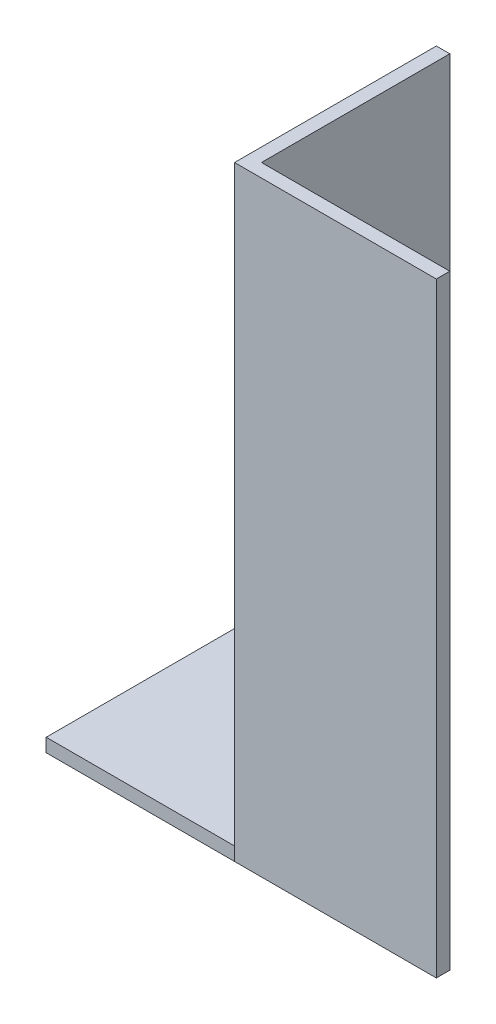
from build123d import *

# Parameters (mm, degrees)
EXTRUDE_1_DEPTH     = 65
SKETCH_3_W          = 1
SKETCH_3_H          = 14
CUT_EXTRUDE_1_DEPTH = 20
SKETCH_5_W          = 14
SKETCH_5_H          = 1
EXTRUDE_4_DEPTH     = 16
SKETCH_6_W          = 15
SKETCH_6_H          = 1
CUT_EXTRUDE_2_DEPTH = 19
SKETCH_7_W          = 15
SKETCH_7_H          = 1
CUT_EXTRUDE_3_DEPTH = 1


with BuildPart() as part:
    # Эскиз1 → Бобышка-Вытянуть1 (new body)
    with BuildSketch(Plane(origin=(0, 0, 0), x_dir=(1, 0, 0), z_dir=(0, 1, 0))):
        Polygon((0, 0), (0, 15), (1, 15), (1, 1), (15, 1), (15, 0), align=None)
    extrude(amount=EXTRUDE_1_DEPTH)

    # Эскиз3 → Вырез-Вытянуть1 (cut)
    with BuildSketch(Plane.XZ):
        with Locations((0.5, -8)):
            Rectangle(SKETCH_3_W, SKETCH_3_H)
    extrude(amount=-CUT_EXTRUDE_1_DEPTH, mode=Mode.SUBTRACT)

    # Эскиз5 → Бобышка-Вытянуть4 (add)
    with BuildSketch(Plane(origin=(1, 0, 0), x_dir=(0, 0, -1), z_dir=(1, 0, 0))):
        with Locations((8, 19.5)):
            Rectangle(SKETCH_5_W, SKETCH_5_H)
    extrude(amount=-EXTRUDE_4_DEPTH)

    # Эскиз6 → Вырез-Вытянуть2 (cut)
    with BuildSketch(Plane.XZ):
        with Locations((7.5, -0.5)):
            Rectangle(SKETCH_6_W, SKETCH_6_H)
    extrude(amount=-CUT_EXTRUDE_2_DEPTH, mode=Mode.SUBTRACT)

    # Эскиз7 → Вырез-Вытянуть3 (cut)
    with BuildSketch(Plane.XZ.offset(-19)):
        with Locations((7.5, -0.5)):
            Rectangle(SKETCH_7_W, SKETCH_7_H)
    extrude(amount=-CUT_EXTRUDE_3_DEPTH, mode=Mode.SUBTRACT)


solid = part.part
